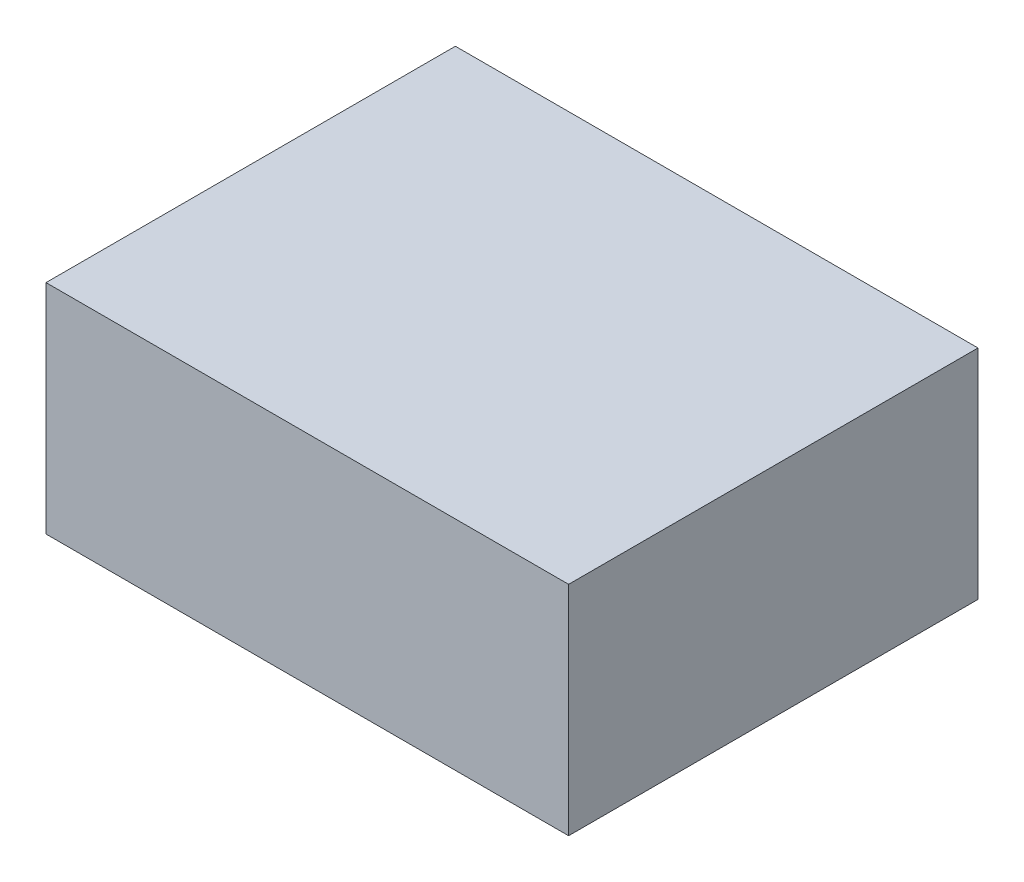
from build123d import *

# Parameters (mm, degrees)
SKETCH1_W           = 23.5
SKETCH1_H           = 12.5
BOSS_EXTRUDE1_DEPTH = 30


with BuildPart() as part:
    # Sketch1 → Boss-Extrude1 (new body)
    with BuildSketch(Plane(origin=(0, 0, 0), x_dir=(0, 0, -1), z_dir=(1, 0, 0))):
        Rectangle(SKETCH1_W, SKETCH1_H)
    extrude(amount=BOSS_EXTRUDE1_DEPTH)


solid = part.part
